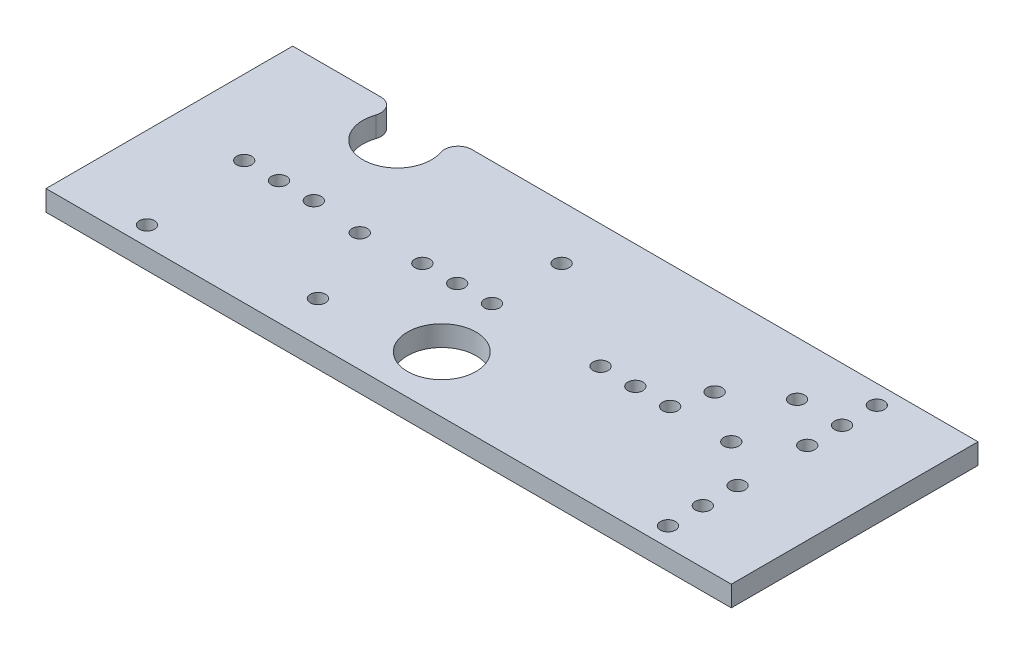
from build123d import *

# Parameters (mm, degrees)
SKETCH1_W           = 50
SKETCH1_H           = 18
BOSS_EXTRUDE1_DEPTH = 1.5
SKETCH2_R           = 2.5
CUT_EXTRUDE1_DEPTH  = 10
SKETCH3_R           = 0.55
CUT_EXTRUDE2_DEPTH  = 2.5
SKETCH4_R           = 0.55
CUT_EXTRUDE3_DEPTH  = 2.5
SKETCH8_R           = 0.55
CUT_EXTRUDE5_DEPTH  = 2.5
FILLET2_R           = 1


with BuildPart() as part:
    # Sketch1 → Boss-Extrude1 (new body)
    with BuildSketch(Plane(origin=(0, 0, 0), x_dir=(1, 0, 0), z_dir=(0, 1, 0))):
        Rectangle(SKETCH1_W, SKETCH1_H)
    extrude(amount=BOSS_EXTRUDE1_DEPTH)

    # Sketch2 → Cut-Extrude1 (cut)
    with BuildSketch(Plane(origin=(0, 1.5, 0), x_dir=(1, 0, 0), z_dir=(0, 1, 0))):
        with Locations((-15.25, 6.875)):
            Circle(SKETCH2_R)
        with Locations((-0.25, -4.875)):
            Circle(SKETCH2_R)
    extrude(amount=-CUT_EXTRUDE1_DEPTH, mode=Mode.SUBTRACT)

    # Sketch3 → Cut-Extrude2 (cut, through all)
    with BuildSketch(Plane.XZ):
        with Locations((-17, 0)):
            Circle(SKETCH3_R)
        with Locations((-4, 0)):
            Circle(SKETCH3_R)
        with Locations((9, 0)):
            Circle(SKETCH3_R)
        with Locations((-19.54, 0)):
            Circle(SKETCH3_R)
        with Locations((-14.46, 0)):
            Circle(SKETCH3_R)
        with Locations((-6.54, 0)):
            Circle(SKETCH3_R)
        with Locations((-1.46, 0)):
            Circle(SKETCH3_R)
        with Locations((6.46, 0)):
            Circle(SKETCH3_R)
        with Locations((11.54, 0)):
            Circle(SKETCH3_R)
    extrude(amount=-CUT_EXTRUDE2_DEPTH, mode=Mode.SUBTRACT)

    # Sketch4 → Cut-Extrude3 (cut, through all)
    with BuildSketch(Plane(origin=(0, 1.5, 0), x_dir=(1, 0, 0), z_dir=(0, 1, 0))):
        with Locations((19, -2.54)):
            Circle(SKETCH4_R)
        with Locations((19, -5.08)):
            Circle(SKETCH4_R)
        with Locations((19, -7.62)):
            Circle(SKETCH4_R)
        with Locations((19, 2.54)):
            Circle(SKETCH4_R)
        with Locations((19, 5.08)):
            Circle(SKETCH4_R)
        with Locations((19, 7.62)):
            Circle(SKETCH4_R)
        with Locations((16, 0)):
            Circle(SKETCH4_R)
    extrude(amount=-CUT_EXTRUDE3_DEPTH, mode=Mode.SUBTRACT)

    # Sketch8 → Cut-Extrude5 (cut, through all)
    with BuildSketch(Plane(origin=(0, 1.5, 0), x_dir=(1, 0, 0), z_dir=(0, 1, 0))):
        with Locations((-10.756904198, -0.352285973)):
            Circle(SKETCH8_R)
        with Locations((-8.129113164, -6.033080496)):
            Circle(SKETCH8_R)
        with Locations((-19.014042493, -7.62)):
            Circle(SKETCH8_R)
        with Locations((-1.46, 5.08)):
            Circle(SKETCH8_R)
        with Locations((12.244030361, 2.54)):
            Circle(SKETCH8_R)
        with Locations((15.717799533, 5.08)):
            Circle(SKETCH8_R)
    extrude(amount=-CUT_EXTRUDE5_DEPTH, mode=Mode.SUBTRACT)

    # Fillet2
    fillet2_edges = [part.edges().sort_by_distance(p)[0] for p in [
        (-13.933043281, 0.75, -9),
        (-16.566956719, 0.75, -9),
    ]]
    fillet(fillet2_edges, radius=FILLET2_R)


solid = part.part
